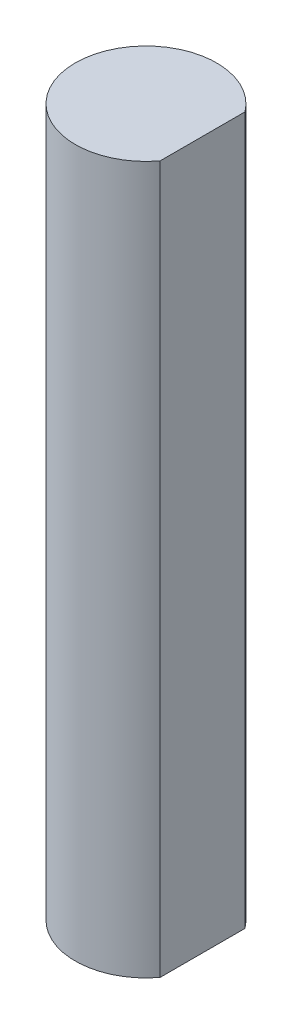
from build123d import *

# Parameters (mm, degrees)
BOSS_EXTRUDE1_DEPTH = 31.75


with BuildPart() as part:
    # Sketch1 → Boss-Extrude1 (new body)
    with BuildSketch(Plane(origin=(0, 0, 0), x_dir=(1, 0, 0), z_dir=(0, 1, 0))):
        with BuildLine():
            Line((2.54, -1.905), (2.54, 1.905))
            ThreePointArc((2.54, 1.905), (-3.175, 0), (2.54, -1.905))
        make_face()
    extrude(amount=BOSS_EXTRUDE1_DEPTH)


solid = part.part
